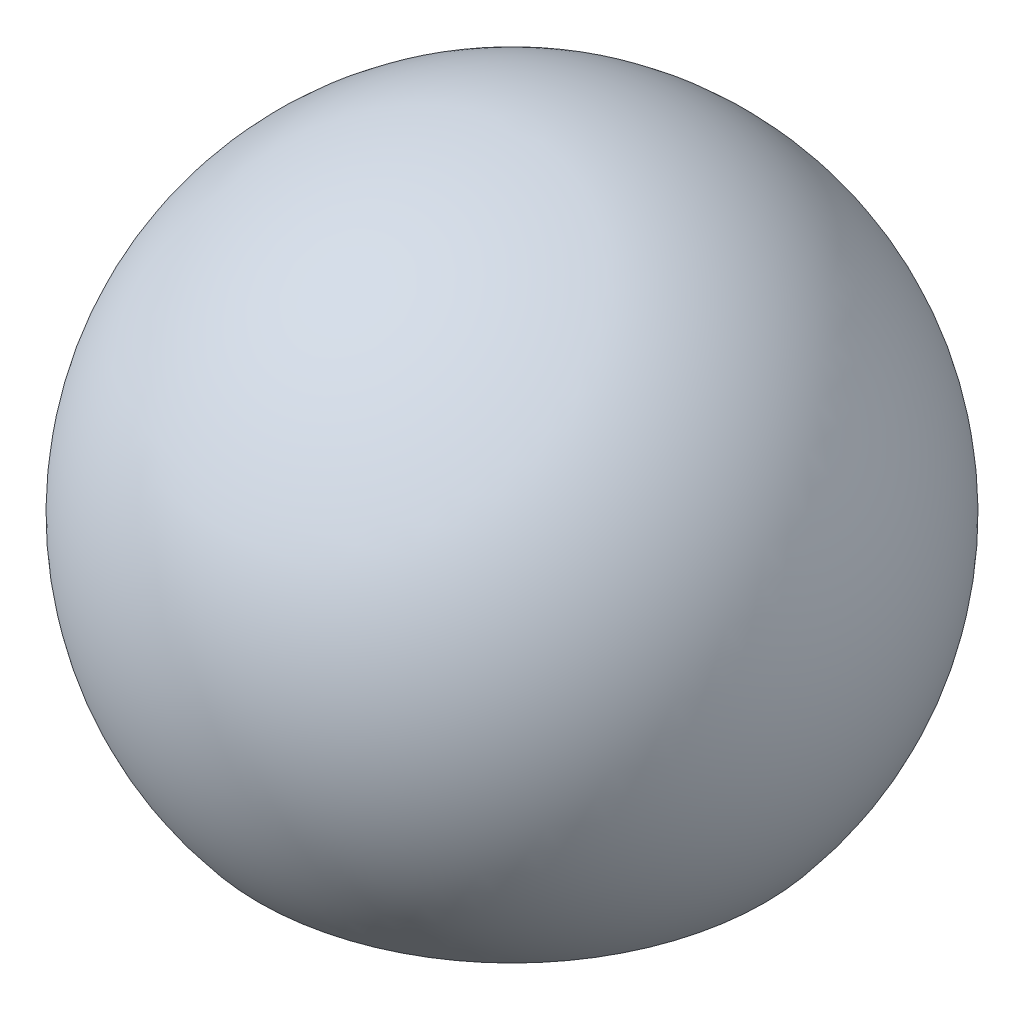
from build123d import *


with BuildPart() as part:
    # Sketch1 → Revolve1 (revolve)
    with BuildSketch(Plane.XY):
        with BuildLine():
            Line((0, 130.2237985), (0, -83.416051786))
            Line((0, -83.416051786), (-100, -83.416051786))
            ThreePointArc((-100, -83.416051786), (-117.942767508, 55.206351882), (0, 130.2237985))
        make_face()
    revolve(axis=Axis((0, 130.2237985, 0), (0, -1, 0)))


solid = part.part
